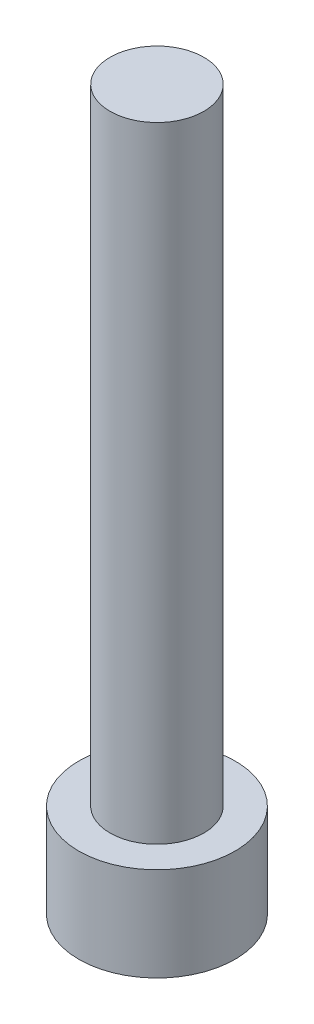
from build123d import *

# Parameters (mm, degrees)
SKETCH_1_R          = 2.5
EXTRUDE_1_DEPTH     = 3
SKETCH_2_R          = 1.5
EXTRUDE_2_DEPTH     = 20
CUT_EXTRUDE_1_DEPTH = 1.65


with BuildPart() as part:
    # 草图1 → 凸台-拉伸1 (new body)
    with BuildSketch(Plane(origin=(0, 0, 0), x_dir=(1, 0, 0), z_dir=(0, 1, 0))):
        Circle(SKETCH_1_R)
    extrude(amount=EXTRUDE_1_DEPTH)

    # 草图2 → 凸台-拉伸2 (add)
    with BuildSketch(Plane(origin=(0, 3, 0), x_dir=(1, 0, 0), z_dir=(0, 1, 0))):
        Circle(SKETCH_2_R)
    extrude(amount=EXTRUDE_2_DEPTH)

    # 草图3 → 切除-拉伸1 (cut)
    with BuildSketch(Plane.XZ):
        Polygon((1.425, 0), (0.7125, 1.2340862), (-0.7125, 1.2340862), (-1.425, 0), (-0.7125, -1.2340862), (0.7125, -1.2340862), align=None)
    extrude(amount=-CUT_EXTRUDE_1_DEPTH, mode=Mode.SUBTRACT)


solid = part.part
